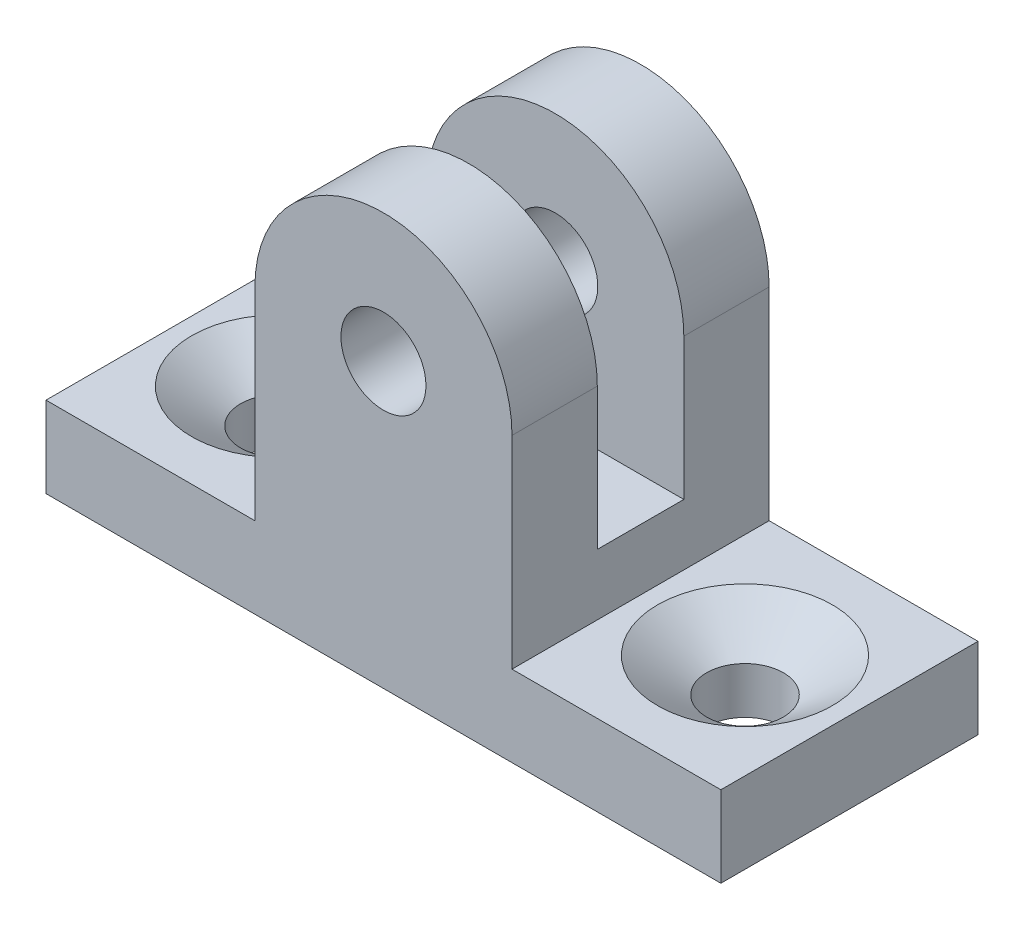
from build123d import *

# Parameters (mm, degrees)
SKETCH1_R           = 1.575
BOSS_EXTRUDE1_DEPTH = 9.525
SKETCH2_W           = 3.205
SKETCH2_H           = 10
CUT_EXTRUDE4_DEPTH  = 9.525
SKETCH4_R           = 1.4224
CUT_EXTRUDE5_DEPTH  = 3
SKETCH5_R           = 3.2385
CUT_EXTRUDE6_DEPTH  = 2.2
CUT_EXTRUDE6_TAPER  = 55


with BuildPart() as part:
    # Sketch1 → Boss-Extrude1 (new body)
    with BuildSketch(Plane.XY):
        with BuildLine():
            Line((4.7625, 10.5), (4.7625, 3))
            Line((4.7625, 3), (12.5, 3))
            Line((12.5, 3), (12.5, 0))
            Line((12.5, 0), (-12.5, 0))
            Line((-12.5, 0), (-12.5, 3))
            Line((-12.5, 3), (-4.7625, 3))
            Line((-4.7625, 3), (-4.7625, 10.5))
            ThreePointArc((-4.7625, 10.5), (0, 15.2625), (4.7625, 10.5))
        make_face()
        with Locations((0, 10.5)):
            Circle(SKETCH1_R, mode=Mode.SUBTRACT)
    extrude(amount=BOSS_EXTRUDE1_DEPTH)

    # Sketch2 → Cut-Extrude4 (cut)
    with BuildSketch(Plane.ZY.offset(4.7625)):
        with Locations((4.7625, 10.2625)):
            Rectangle(SKETCH2_W, SKETCH2_H)
    extrude(amount=-CUT_EXTRUDE4_DEPTH, mode=Mode.SUBTRACT)

    # Sketch4 → Cut-Extrude5 (cut)
    with BuildSketch(Plane(origin=(0, 3, 0), x_dir=(1, 0, 0), z_dir=(0, 1, 0))):
        with Locations((8.63125, -4.7625)):
            Circle(SKETCH4_R)
        with Locations((-8.63125, -4.7625)):
            Circle(SKETCH4_R)
    extrude(amount=-CUT_EXTRUDE5_DEPTH, mode=Mode.SUBTRACT)

    # Sketch5 → Cut-Extrude6 (cut)
    with BuildSketch(Plane(origin=(0, 3, 0), x_dir=(1, 0, 0), z_dir=(0, 1, 0))):
        with Locations((8.63125, -4.7625)):
            Circle(SKETCH5_R)
        with Locations((-8.63125, -4.7625)):
            Circle(SKETCH5_R)
    extrude(amount=-CUT_EXTRUDE6_DEPTH, taper=CUT_EXTRUDE6_TAPER, mode=Mode.SUBTRACT)


solid = part.part
